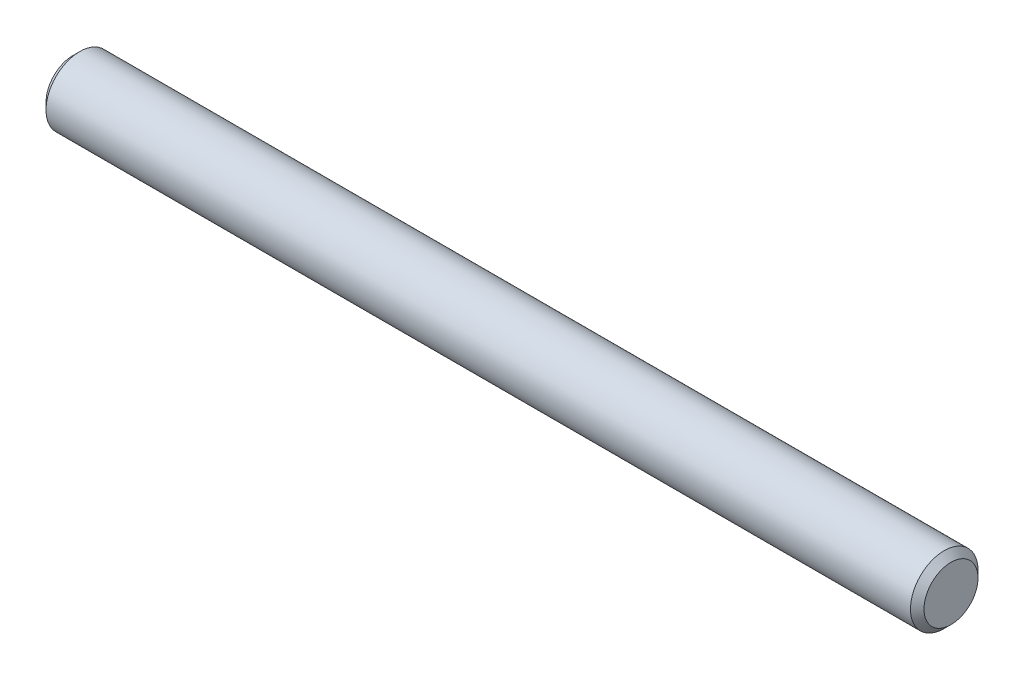
from build123d import *

# Parameters (mm, degrees)
SKETCH2_R           = 1.5875
EXTRUDE1_DEPTH      = 20.6375
EXTRUDE1_DEPTH_BACK = 20.6375
CHAMFER1_SIZE       = 0.3175


with BuildPart() as part:
    # Sketch2 → Extrude1 (new body, two sides)
    with BuildSketch(Plane(origin=(0, 0, 0), x_dir=(0, 0, -1), z_dir=(1, 0, 0))) as extrude1_sk:
        Circle(SKETCH2_R)
    extrude(amount=EXTRUDE1_DEPTH)
    extrude(extrude1_sk.sketch, amount=-EXTRUDE1_DEPTH_BACK)

    # Chamfer1
    chamfer1_edges = [part.edges().sort_by_distance(p)[0] for p in [
        (-20.6375, 0, 1.5875),
        (20.6375, 0, 1.5875),
    ]]
    chamfer(chamfer1_edges, length=CHAMFER1_SIZE)


solid = part.part
